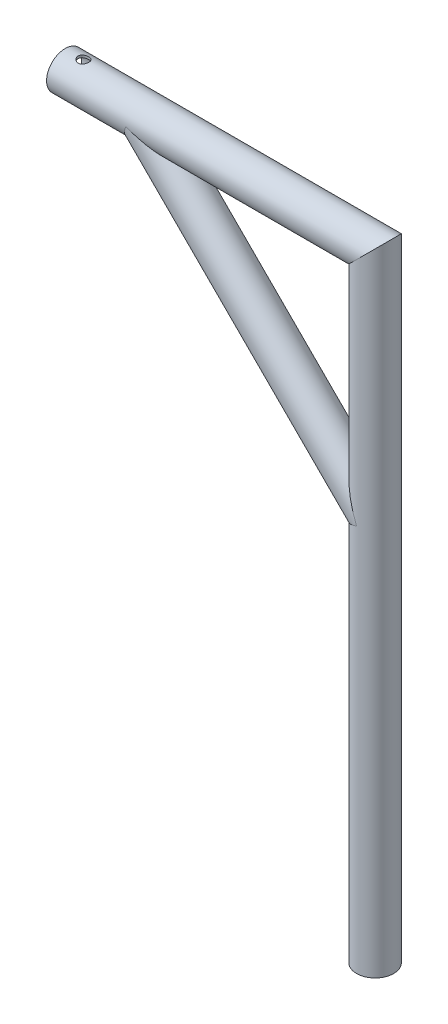
from build123d import *

# Parameters (mm, degrees)
SKETCH2_R                       = 24
SKETCH2_R_2                     = 21
EXTRUDE_THIN4_REACH             = 583.242
SKETCH3_R                       = 24
SKETCH3_R_2                     = 22
EXTRUDE_THIN4_DIRECTION_2_REACH = 301.813
SKETCH4_R                       = 7
CUT_EXTRUDE1_DEPTH              = 823


with BuildPart() as part:
    # Sweep-Thin1: sweep along a path in Sketch1
    with BuildLine(Plane.XY) as sweep_thin1_path:
        Line((0, 0), (0, 798))
        Line((0, 798), (-400, 798))
    # Sketch2 → Sweep-Thin1 (sweep)
    with BuildSketch(Plane(origin=(0, 0, 0), x_dir=(1, 0, 0), z_dir=(0, 1, 0))):
        Circle(SKETCH2_R)
        Circle(SKETCH2_R_2, mode=Mode.SUBTRACT)
    sweep(path=sweep_thin1_path.line, transition=Transition.RIGHT)

    # Sketch3 → Extrude-Thin4 (add, up to next)
    with BuildSketch(Plane(origin=(-399, 399, 0), x_dir=(0, 0, -1), z_dir=(0.707106781, -0.707106781, 0)), mode=Mode.PRIVATE) as extrude_thin4_sk1:
        with Locations((0, 353.781901472)):
            Circle(SKETCH3_R)
        with Locations((0, 353.781901472)):
            Circle(SKETCH3_R_2, mode=Mode.SUBTRACT)
    extrude_thin4_tool1 = extrude(extrude_thin4_sk1.sketch, amount=EXTRUDE_THIN4_REACH, mode=Mode.PRIVATE) - part.part
    add(extrude_thin4_tool1.solids().sort_by_distance((-148.838418, 649.161582, 23.321177))[0])

    # Sketch3 → Extrude-Thin4 direction 2 (add, up to next)
    with BuildSketch(Plane(origin=(-399, 399, 0), x_dir=(0, 0, -1), z_dir=(0.707106781, -0.707106781, 0)), mode=Mode.PRIVATE) as extrude_thin4_direction_2_sk1:
        with Locations((0, 353.781901472)):
            Circle(SKETCH3_R)
        with Locations((0, 353.781901472)):
            Circle(SKETCH3_R_2, mode=Mode.SUBTRACT)
    extrude_thin4_direction_2_tool1 = extrude(extrude_thin4_direction_2_sk1.sketch, amount=-EXTRUDE_THIN4_DIRECTION_2_REACH, mode=Mode.PRIVATE) - part.part
    add(extrude_thin4_direction_2_tool1.solids().sort_by_distance((-148.838418, 649.161582, 23.321177))[0])

    # Sketch4 → Cut-Extrude1 (cut, through all)
    with BuildSketch(Plane(origin=(0, 0, 0), x_dir=(1, 0, 0), z_dir=(0, 1, 0))):
        with Locations((-376.34, 0)):
            Circle(SKETCH4_R)
    extrude(amount=CUT_EXTRUDE1_DEPTH, mode=Mode.SUBTRACT)


solid = part.part
